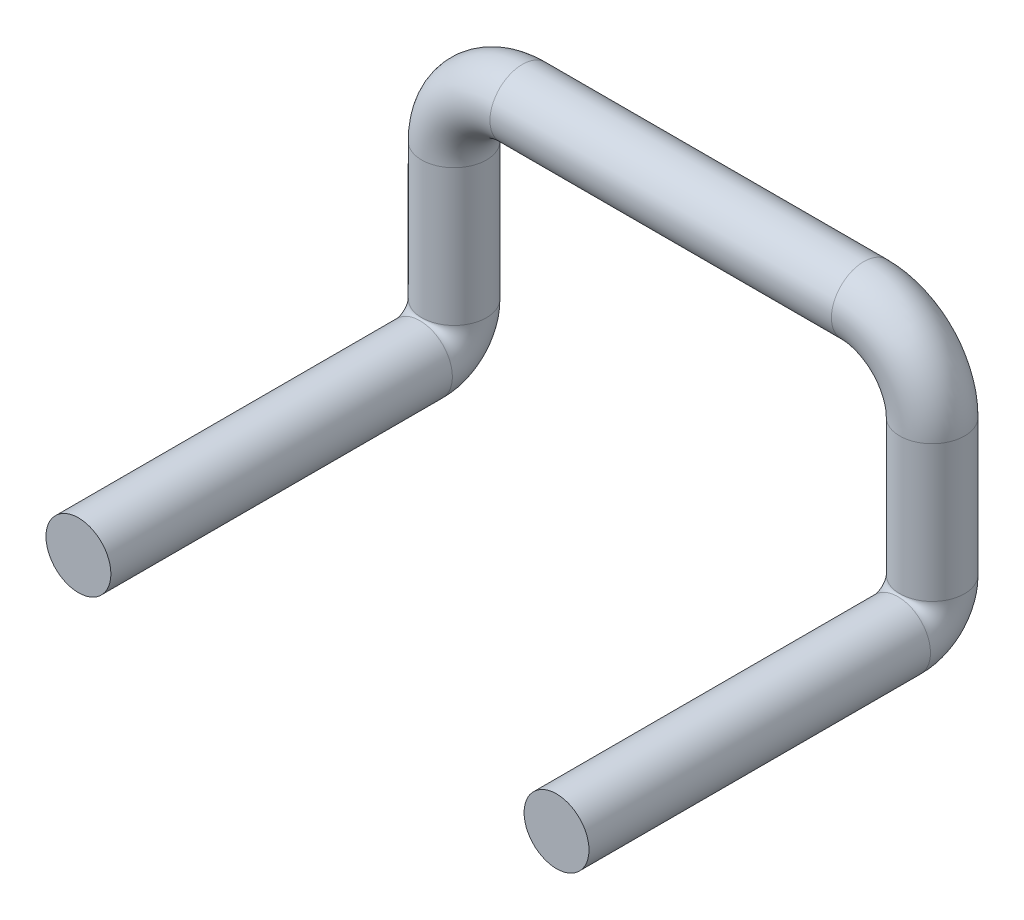
from build123d import *

# Parameters (mm, degrees)
SWEEP5_PROFILE_R = 0.95
SWEEP6_PROFILE_R = 0.95
SWEEP7_PROFILE_R = 0.95


with BuildPart() as part:
    # Sweep5: sweep along a path in Sketch1
    with BuildLine(Plane.XY) as sweep5_path:
        Line((0, 0), (0, 4))
        ThreePointArc((0, 4), (0.585786438, 5.414213562), (2, 6))
        Line((2, 6), (12, 6))
        ThreePointArc((12, 6), (13.414213562, 5.414213562), (14, 4))
        Line((14, 4), (14, 0))
    # Sweep5 profile (on start of the path) → Sweep5 (sweep)
    with BuildSketch(Plane.ZX):
        Circle(SWEEP5_PROFILE_R)
    sweep(path=sweep5_path.line)

    # Sweep6: sweep along a path in Sketch3
    with BuildLine(Plane(origin=(14, 0, 0), x_dir=(0, -1, 0), z_dir=(-1, 0, 0))) as sweep6_path:
        Line((1, 11), (1, 1))
        ThreePointArc((1, 1), (0.707106781, 0.292893219), (0, 0))
    # Sweep6 profile (on start of the path) → Sweep6 (sweep)
    with BuildSketch(Plane(origin=(14, -1, 11), x_dir=(0, -1, 0), z_dir=(0, 0, -1))):
        Circle(SWEEP6_PROFILE_R)
    sweep(path=sweep6_path.line)

    # Sweep7: sweep along a path in Sketch2
    with BuildLine(Plane(origin=(0, 0, 0), x_dir=(0, 0, -1), z_dir=(1, 0, 0))) as sweep7_path:
        Line((-11, -1), (-1, -1))
        ThreePointArc((-1, -1), (-0.292893219, -0.707106781), (0, 0))
    # Sweep7 profile (on start of the path) → Sweep7 (sweep)
    with BuildSketch(Plane(origin=(0, -1, 11), x_dir=(0, -1, 0), z_dir=(0, 0, -1))):
        Circle(SWEEP7_PROFILE_R)
    sweep(path=sweep7_path.line)


solid = part.part
